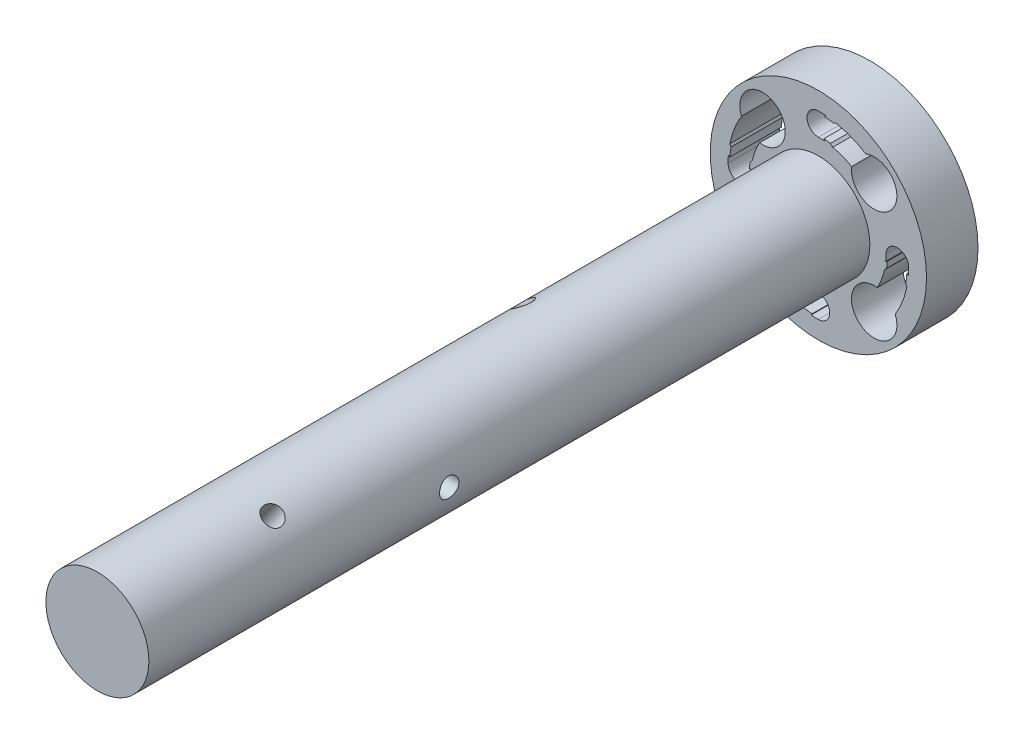
from build123d import *

# Parameters (mm, degrees)
SKETCH1_R               = 4.7625
BOSS_EXTRUDE1_DEPTH     = 66.675
SKETCH1_4_R             = 9.999999939
SKETCH1_4_R_2           = 3.175
BOSS_EXTRUDE2_DEPTH     = 4.7625
FILLET1_R               = 3.175
SKETCH3_R               = 0.899999978
CUT_EXTRUDE2_DEPTH      = 10.999999939
CUT_EXTRUDE2_DEPTH_BACK = 10.999999939
SKETCH4_R               = 0.899999978
CUT_EXTRUDE3_DEPTH      = 14.927284721
CUT_EXTRUDE3_DEPTH_BACK = 14.927284721
SKETCH5_R               = 0.899999978
CUT_EXTRUDE4_DEPTH      = 14.927284721
CUT_EXTRUDE4_DEPTH_BACK = 14.927284721
CUT_EXTRUDE5_DEPTH      = 72.4375001
BOSS_EXTRUDE3_DEPTH     = 4.7625
CIRPATTERN1_COUNT       = 4


with BuildPart() as part:
    # Sketch1 → Boss-Extrude1 (new body)
    with BuildSketch(Plane.XY):
        Circle(SKETCH1_R)
    extrude(amount=BOSS_EXTRUDE1_DEPTH)

    # Sketch1_4 → Boss-Extrude2 (add)
    with BuildSketch(Plane.XY):
        Circle(SKETCH1_4_R)
        Circle(SKETCH1_4_R_2, mode=Mode.SUBTRACT)
    extrude(amount=-BOSS_EXTRUDE2_DEPTH)

    # Fillet1
    fillet1_edges = [part.edges().sort_by_distance(p)[0] for p in [
        (-3.175, 0, 0),
    ]]
    fillet(fillet1_edges, radius=FILLET1_R)

    # Sketch3 → Cut-Extrude2 (cut, two sides)
    with BuildSketch(Plane(origin=(0, 0, 0), x_dir=(0, 0, -1), z_dir=(1, 0, 0))) as cut_extrude2_sk:
        with Locations((-38.89375, 0)):
            Circle(SKETCH3_R)
    extrude(amount=CUT_EXTRUDE2_DEPTH, mode=Mode.SUBTRACT)
    extrude(cut_extrude2_sk.sketch, amount=-CUT_EXTRUDE2_DEPTH_BACK, mode=Mode.SUBTRACT)

    # Sketch4 → Cut-Extrude3 (cut, two sides)
    with BuildSketch(Plane(origin=(0, 0, 0), x_dir=(0, 0, -1), z_dir=(0.573576436, 0.819152044, 0))) as cut_extrude3_sk:
        with Locations((-53.18125, 0)):
            Circle(SKETCH4_R)
    extrude(amount=CUT_EXTRUDE3_DEPTH, mode=Mode.SUBTRACT)
    extrude(cut_extrude3_sk.sketch, amount=-CUT_EXTRUDE3_DEPTH_BACK, mode=Mode.SUBTRACT)

    # Sketch5 → Cut-Extrude4 (cut, two sides)
    with BuildSketch(Plane(origin=(0, 0, 0), x_dir=(0, 0, -1), z_dir=(-0.573576436, 0.819152044, 0))) as cut_extrude4_sk:
        with Locations((-24.60625, 0)):
            Circle(SKETCH5_R)
    extrude(amount=CUT_EXTRUDE4_DEPTH, mode=Mode.SUBTRACT)
    extrude(cut_extrude4_sk.sketch, amount=-CUT_EXTRUDE4_DEPTH_BACK, mode=Mode.SUBTRACT)

    # Sketch6 → Cut-Extrude5 (cut, through all)
    with BuildSketch(Plane(origin=(0, 0, -4.7625), x_dir=(-1, 0, 0), z_dir=(0, 0, -1))):
        with BuildLine():
            ThreePointArc((0, 6.249999819), (1.050000059, 7.299999878), (0, 8.349999937))
            ThreePointArc((0, 8.349999937), (-2.275161332, 8.034061231), (-4.378152237, 7.11015344))
            ThreePointArc((-4.378152237, 7.11015344), (-6.820637013, 3.874042781), (-3.080152041, 5.438304988))
            ThreePointArc((-3.080152041, 5.438304988), (-1.592653846, 6.043670364), (0, 6.249999819))
        make_face()
    cut_extrude5 = extrude(amount=-CUT_EXTRUDE5_DEPTH, mode=Mode.SUBTRACT)

    # Sketch7 → Boss-Extrude3 (add)
    with BuildSketch(Plane(origin=(0, 0, -4.7625), x_dir=(-1, 0, 0), z_dir=(0, 0, -1))):
        with BuildLine():
            ThreePointArc((-0.506000912, 6.379965531), (-0.809595225, 6.348586667), (-1.111348298, 6.302769396))
            Line((-1.111348298, 6.302769396), (-1.329589914, 6.106937727))
            ThreePointArc((-1.329589914, 6.106937727), (-0.963002055, 6.175364344), (-0.592985752, 6.221805657))
            Line((-0.592985752, 6.221805657), (-0.506000912, 6.379965531))
        make_face()
        with BuildLine():
            Line((-1.632295539, 8.188901649), (-1.423915054, 8.075423558))
            ThreePointArc((-1.423915054, 8.075423558), (-0.999751281, 8.138826519), (-0.57285269, 8.179965741))
            Line((-0.57285269, 8.179965741), (-0.666214637, 8.323380143))
            ThreePointArc((-0.666214637, 8.323380143), (-1.151220385, 8.270259402), (-1.632295539, 8.188901649))
        make_face()
    boss_extrude3 = extrude(amount=-BOSS_EXTRUDE3_DEPTH)

    # CirPattern1: Cut-Extrude5, Boss-Extrude3 ×4 about axis
    cirpattern1_axis = Axis((0, 0, 0), (0, 0, 1))
    for i in range(1, CIRPATTERN1_COUNT):
        add(cut_extrude5.rotate(cirpattern1_axis, i * 360 / CIRPATTERN1_COUNT), mode=Mode.SUBTRACT)
        add(boss_extrude3.rotate(cirpattern1_axis, i * 360 / CIRPATTERN1_COUNT))


solid = part.part
